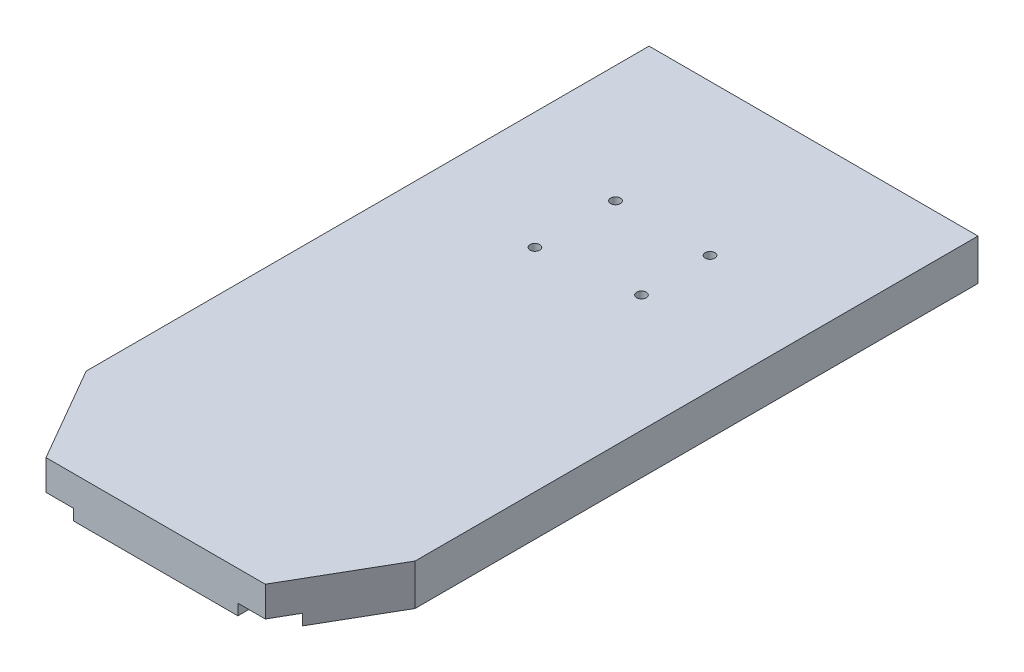
from build123d import *

# Parameters (mm, degrees)
SKETCH1_W             = 152.4
SKETCH1_H             = 304.8
BOSS_EXTRUDE1_DEPTH   = 19.05
F_8_CLEARANCE_HOLE1_D = 4.4958
CUT_EXTRUDE1_DEPTH    = 20.05
SKETCH5_W             = 19.05
SKETCH5_H             = 304.8
CUT_EXTRUDE2_DEPTH    = 5.08


with BuildPart() as part:
    # Sketch1 → Boss-Extrude1 (new body)
    with BuildSketch(Plane(origin=(0, 0, 0), x_dir=(1, 0, 0), z_dir=(0, 1, 0))):
        Rectangle(SKETCH1_W, SKETCH1_H)
    extrude(amount=BOSS_EXTRUDE1_DEPTH)

    # #8 Clearance Hole1 (through all)
    with Locations(Plane(origin=(0, 19.05, 0), x_dir=(1, 0, 0), z_dir=(0, 1, 0))):
        with Locations((-21.89, 82.55), (21.89, 82.55), (-21.89, 45.212), (21.89, 50.8)):
            Hole(F_8_CLEARANCE_HOLE1_D / 2)

    # Sketch4 → Cut-Extrude1 (cut, through all)
    with BuildSketch(Plane.XZ):
        Polygon((76.2, 152.4), (50.8, 152.4), (76.2, 108.405909488), align=None)
        Polygon((-76.2, 108.405909488), (-50.8, 152.4), (-76.2, 152.4), align=None)
    extrude(amount=-CUT_EXTRUDE1_DEPTH, mode=Mode.SUBTRACT)

    # Sketch5 → Cut-Extrude2 (cut)
    with BuildSketch(Plane.XZ):
        with Locations((47.625, 0)):
            Rectangle(SKETCH5_W, SKETCH5_H)
        with Locations((-47.625, 0)):
            Rectangle(SKETCH5_W, SKETCH5_H)
    extrude(amount=-CUT_EXTRUDE2_DEPTH, mode=Mode.SUBTRACT)


solid = part.part
